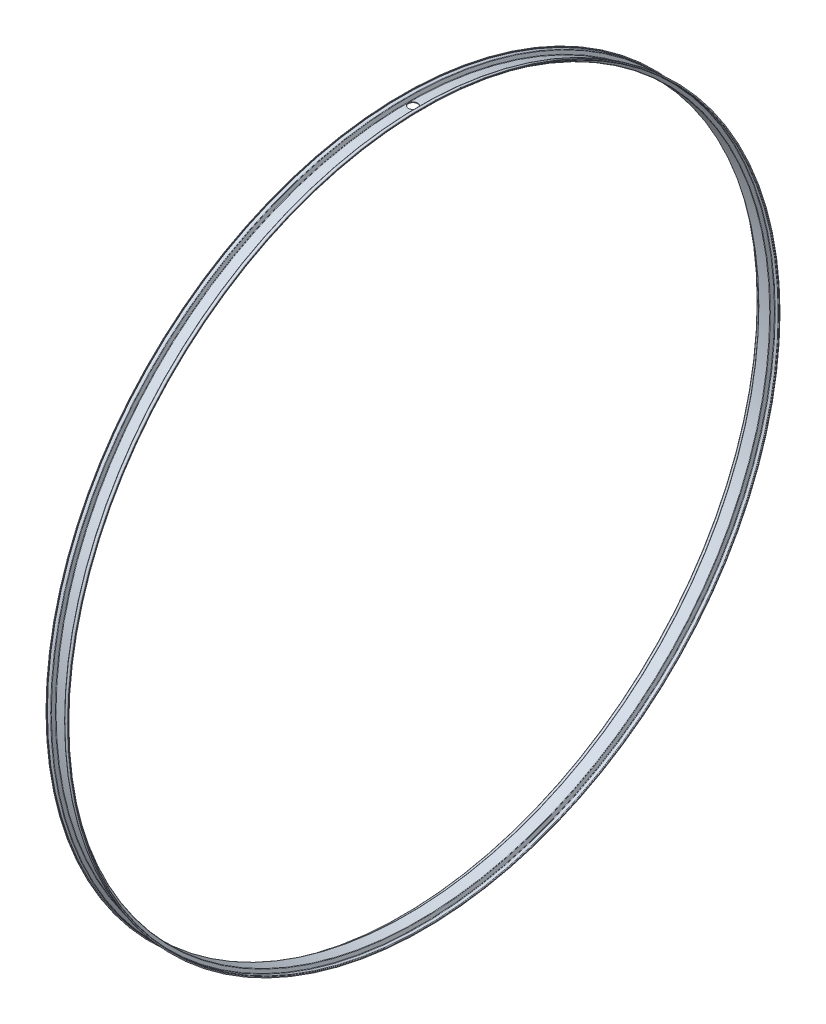
from build123d import *

# Parameters (mm, degrees)
CONG_1_R                = 0.5
ESQUISSE2_R             = 4
ENL_V_MAT_EXTRU_1_DEPTH = 311.7


with BuildPart() as part:
    # Esquisse1 → Révolution1 (revolve)
    with BuildSketch(Plane.XY, mode=Mode.PRIVATE) as r_volution1_sk:
        Polygon((-9.5, 309.5), (-6.25, 309.5), (-5, 306.5), (5, 306.5), (6.25, 309.5), (9.5, 309.5), (9.5, 310.7), (9, 310.7), (9, 310), (5.916666667, 310), (4.666666667, 307), (-4.666666667, 307), (-5.916666667, 310), (-9, 310), (-9, 310.7), (-9.5, 310.7), align=None)
    revolve(r_volution1_sk.sketch.rotate(Axis((-11.232892416, 0, 0), (1, 0, 0)), 90), axis=Axis((-11.232892416, 0, 0), (1, 0, 0)))  # turned: the seam where the file's is

    # Congé1
    cong_1_edges = [part.edges().sort_by_distance(p)[0] for p in [
        (-5.916666667, 0, -310),
        (-4.666666667, 0, -307),
        (4.666666667, 0, -307),
        (5.916666667, 0, -310),
        (9.5, 0, -309.5),
        (6.25, 0, -309.5),
        (5, 0, -306.5),
        (-5, 0, -306.5),
        (-6.25, 0, -309.5),
        (-9.5, 0, -309.5),
    ]]
    fillet(cong_1_edges, radius=CONG_1_R)

    # Esquisse2 → Enlèv. mat.-Extru.1 (cut, through all)
    with BuildSketch(Plane(origin=(0, 0, 0), x_dir=(1, 0, 0), z_dir=(0, 1, 0))):
        with Locations(Location((0, 0, 0), (0, 0, 90))):  # turned: the seam where the file's is
            Circle(ESQUISSE2_R)
    extrude(amount=ENL_V_MAT_EXTRU_1_DEPTH, mode=Mode.SUBTRACT)


solid = part.part
